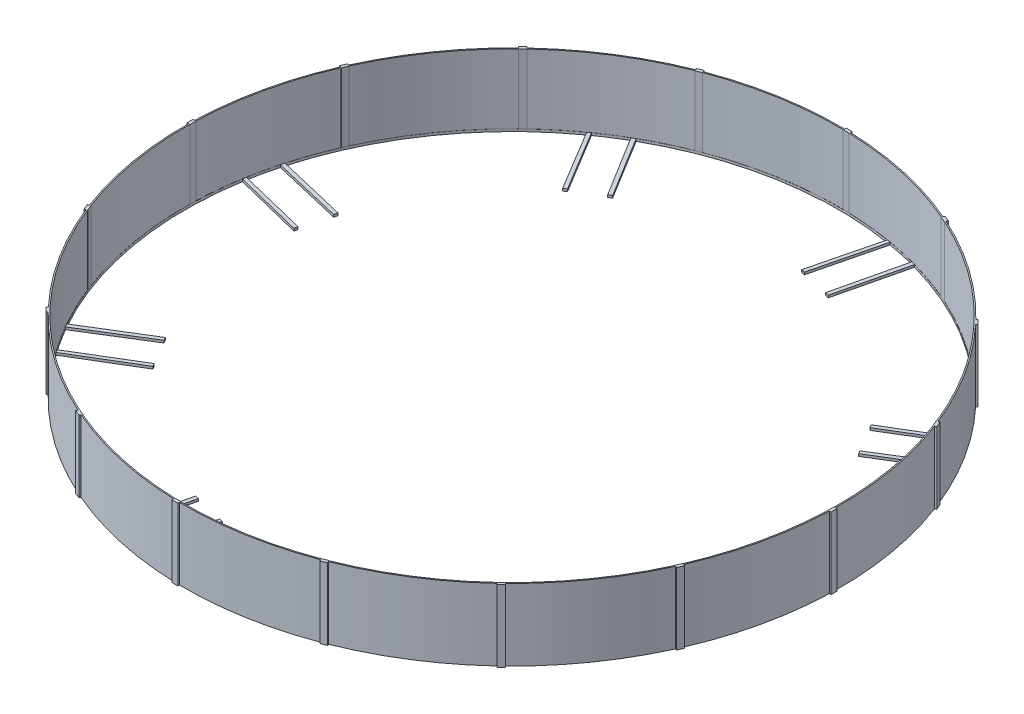
from build123d import *

# Parameters (mm, degrees)
SKETCH2_R           = 27500
BOSS_EXTRUDE1_DEPTH = 6000
SKETCH3_R           = 27400
CUT_EXTRUDE1_DEPTH  = 5800
SKETCH6_W           = 500
SKETCH6_H           = 6000
BOSS_EXTRUDE2_DEPTH = 125
CIRPATTERN1_COUNT   = 16
SKETCH8_R           = 27390
CUT_EXTRUDE2_DEPTH  = 6227
BOSS_EXTRUDE3_DEPTH = 200
CIRPATTERN2_COUNT   = 8
FILLET1_R           = 20
FILLET2_R           = 20


with BuildPart() as part:
    # Sketch2 → Boss-Extrude1 (new body)
    with BuildSketch(Plane(origin=(0, 0, 0), x_dir=(1, 0, 0), z_dir=(0, 1, 0))):
        Circle(SKETCH2_R)
    extrude(amount=BOSS_EXTRUDE1_DEPTH)

    # Sketch3 → Cut-Extrude1 (cut)
    with BuildSketch(Plane(origin=(0, 6000, 0), x_dir=(1, 0, 0), z_dir=(0, 1, 0))):
        Circle(SKETCH3_R)
    extrude(amount=-CUT_EXTRUDE1_DEPTH, mode=Mode.SUBTRACT)

    # Sketch6 → Boss-Extrude2 (add, symmetric)
    with BuildSketch(Plane(origin=(27500, 0, 0), x_dir=(0, 0, -1), z_dir=(1, 0, 0))):
        with Locations((-637.678148973, 3000)):
            Rectangle(SKETCH6_W, SKETCH6_H)
    boss_extrude2 = extrude(amount=BOSS_EXTRUDE2_DEPTH, both=True)

    # CirPattern1: Boss-Extrude2 ×16 about axis
    cirpattern1_axis = Axis((-0.099838763, 0, -0.002222088), (0, 1, 0))
    for i in range(1, CIRPATTERN1_COUNT):
        add(boss_extrude2.rotate(cirpattern1_axis, i * 360 / CIRPATTERN1_COUNT))

    # Sketch8 → Cut-Extrude2 (cut)
    with BuildSketch(Plane(origin=(0, 200, 0), x_dir=(1, 0, 0), z_dir=(0, 1, 0))):
        Circle(SKETCH8_R)
    extrude(amount=-CUT_EXTRUDE2_DEPTH, mode=Mode.SUBTRACT)

    # Sketch10 → Boss-Extrude3 (add)
    with BuildSketch(Plane(origin=(0, 0, 0), x_dir=(1, 0, 0), z_dir=(0, 1, 0))):
        Polygon((5674.449471115, 20624.936870229), (5965.678309656, 20552.924624036), (7360.975131582, 26388.399495863), (7045.930869189, 26466.087336938), align=None)
        Polygon((4448.034501077, 27106.711485076), (4723.505956769, 27038.782036925), (3290.003572919, 21212.547091039), (2998.73097018, 21284.382116574), align=None)
    boss_extrude3 = extrude(amount=BOSS_EXTRUDE3_DEPTH)

    # CirPattern2: Boss-Extrude3 ×8 about axis
    cirpattern2_axis = Axis((0, 0, 0), (0, 1, 0))
    for i in range(1, CIRPATTERN2_COUNT):
        add(boss_extrude3.rotate(cirpattern2_axis, i * 360 / CIRPATTERN2_COUNT))

    # Fillet1
    fillet1_edges = [part.edges().sort_by_distance(p)[0] for p in [
        (3144.36727155, 200, -21248.464603806),
    ]]
    fillet(fillet1_edges, radius=FILLET1_R)

    # Fillet2
    fillet2_edges = [part.edges().sort_by_distance(p)[0] for p in [
        (5820.063890386, 200, -20588.930747133),
    ]]
    fillet(fillet2_edges, radius=FILLET2_R)


solid = part.part
